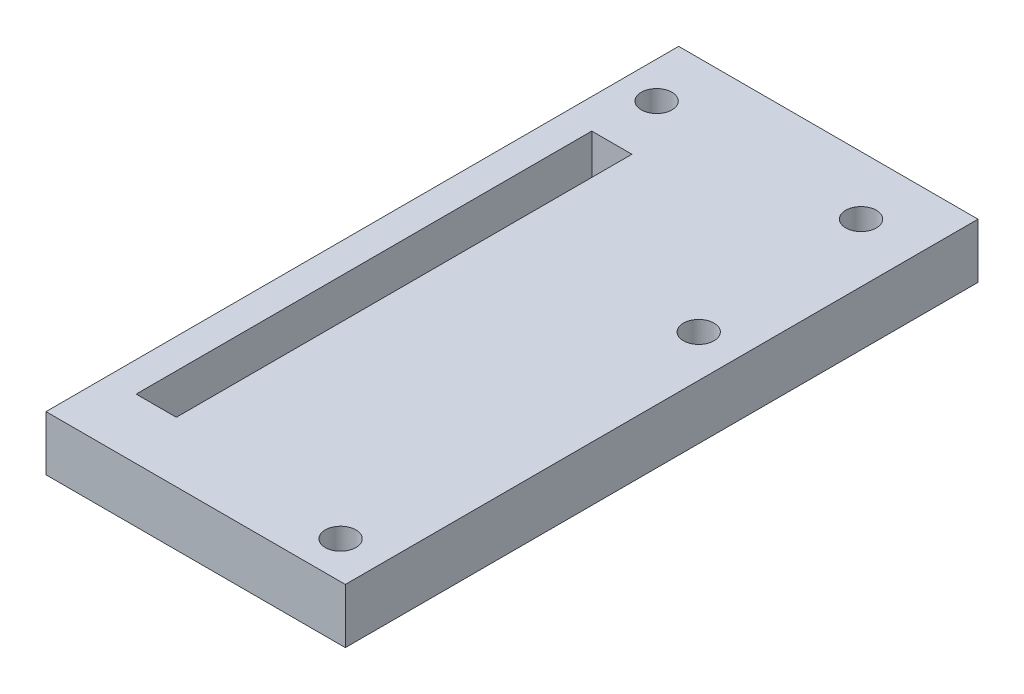
from build123d import *

# Parameters (mm, degrees)
SKETCH1_W           = 50
SKETCH1_H           = 86.65
BOSS_EXTRUDE1_DEPTH = 7.5
SKETCH7_W           = 5.5
SKETCH7_H           = 62.4
CUT_EXTRUDE5_DEPTH  = 5.95
SKETCH11_R          = 2.1
CUT_EXTRUDE8_DEPTH  = 8.5
SKETCH12_R          = 2.1
CUT_EXTRUDE10_DEPTH = 8.5
SKETCH13_W          = 86.65
SKETCH13_H          = 7.5
BOSS_EXTRUDE2_DEPTH = 1
SKETCH14_W          = 86.65
SKETCH14_H          = 7.5
CUT_EXTRUDE11_DEPTH = 10


with BuildPart() as part:
    # Sketch1 → Boss-Extrude1 (new body)
    with BuildSketch(Plane(origin=(0, 0, 0), x_dir=(1, 0, 0), z_dir=(0, 1, 0))):
        Rectangle(SKETCH1_W, SKETCH1_H)
    extrude(amount=BOSS_EXTRUDE1_DEPTH)

    # Sketch7 → Cut-Extrude5 (cut)
    with BuildSketch(Plane(origin=(0, 7.5, 0), x_dir=(1, 0, 0), z_dir=(0, 1, 0))):
        with Locations((-8.15, -3.875)):
            Rectangle(SKETCH7_W, SKETCH7_H)
    extrude(amount=-CUT_EXTRUDE5_DEPTH, mode=Mode.SUBTRACT)

    # Sketch11 → Cut-Extrude8 (cut, through all)
    with BuildSketch(Plane(origin=(0, 7.5, 0), x_dir=(1, 0, 0), z_dir=(0, 1, 0))):
        with Locations((17.982, 35.325)):
            Circle(SKETCH11_R)
        with Locations((-10.018, 35.325)):
            Circle(SKETCH11_R)
    extrude(amount=-CUT_EXTRUDE8_DEPTH, mode=Mode.SUBTRACT)

    # Sketch12 → Cut-Extrude10 (cut, through all)
    with BuildSketch(Plane(origin=(0, 7.5, 0), x_dir=(1, 0, 0), z_dir=(0, 1, 0))):
        with Locations((20.25, 10.821)):
            Circle(SKETCH12_R)
        with Locations((20.25, -38.229)):
            Circle(SKETCH12_R)
    extrude(amount=-CUT_EXTRUDE10_DEPTH, mode=Mode.SUBTRACT)

    # Sketch13 → Boss-Extrude2 (add)
    with BuildSketch(Plane(origin=(25, 0, 0), x_dir=(0, 0, -1), z_dir=(1, 0, 0))):
        with Locations((0, 3.75)):
            Rectangle(SKETCH13_W, SKETCH13_H)
    extrude(amount=BOSS_EXTRUDE2_DEPTH)

    # Sketch14 → Cut-Extrude11 (cut)
    with BuildSketch(Plane.ZY.offset(25)):
        with Locations((0, 3.75)):
            Rectangle(SKETCH14_W, SKETCH14_H)
    extrude(amount=-CUT_EXTRUDE11_DEPTH, mode=Mode.SUBTRACT)


solid = part.part
